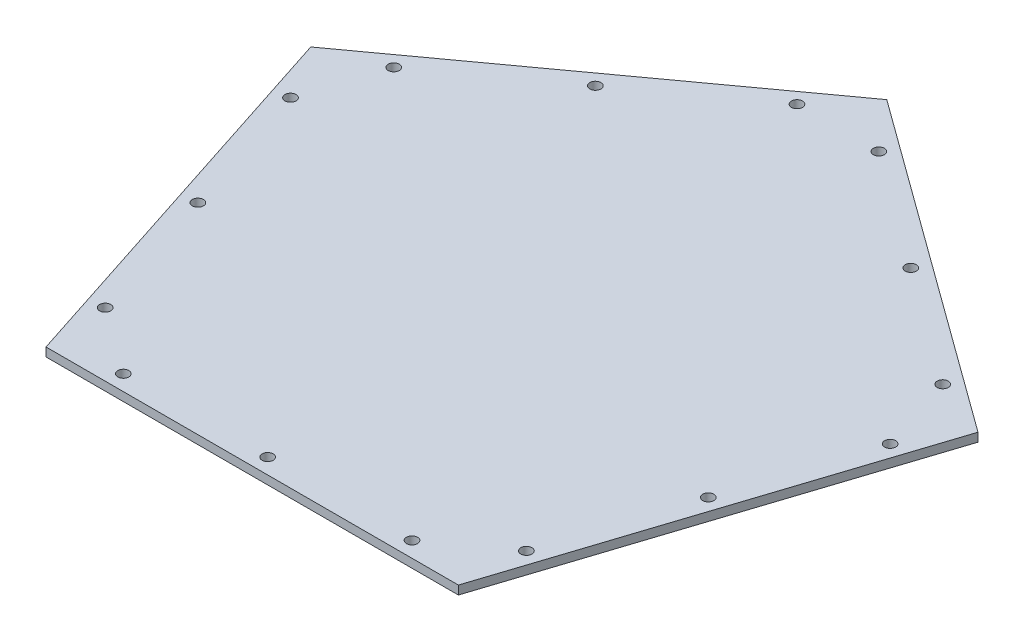
from build123d import *

# Parameters (mm, degrees)
BOSS_EXTRUDE1_DEPTH = 1.3335
SKETCH2_R           = 1.7145
CUT_EXTRUDE1_DEPTH  = 109.065567735
CIRPATTERN1_COUNT   = 5


with BuildPart() as part:
    # Sketch1 → Boss-Extrude1 (new, symmetric)
    with BuildSketch(Plane(origin=(0, 0, 0), x_dir=(1, 0, 0), z_dir=(0, 1, 0))):
        Polygon((0, 0), (-63.5, -87.40025195), (0, -87.40025195), (63.5, -87.40025195), align=None)
    boss_extrude1 = extrude(amount=BOSS_EXTRUDE1_DEPTH, both=True)

    # Sketch2 → Cut-Extrude1 (cut, symmetric)
    with BuildSketch(Plane.XZ.offset(1.3335)):
        with Locations((-44.45, 82.63775195)):
            Circle(SKETCH2_R)
        with Locations((0, 82.63775195)):
            Circle(SKETCH2_R)
        with Locations((44.45, 82.63775195)):
            Circle(SKETCH2_R)
    cut_extrude1 = extrude(amount=CUT_EXTRUDE1_DEPTH, both=True, mode=Mode.SUBTRACT)

    # CirPattern1: Boss-Extrude1, Cut-Extrude1 ×5 about axis
    cirpattern1_axis = Axis((0, 1.3335, 0), (0, -1, 0))
    add([boss_extrude1.rotate(cirpattern1_axis, i * 360 / CIRPATTERN1_COUNT) for i in range(1, CIRPATTERN1_COUNT)])
    add([cut_extrude1.rotate(cirpattern1_axis, i * 360 / CIRPATTERN1_COUNT) for i in range(1, CIRPATTERN1_COUNT)], mode=Mode.SUBTRACT)


solid = part.part
